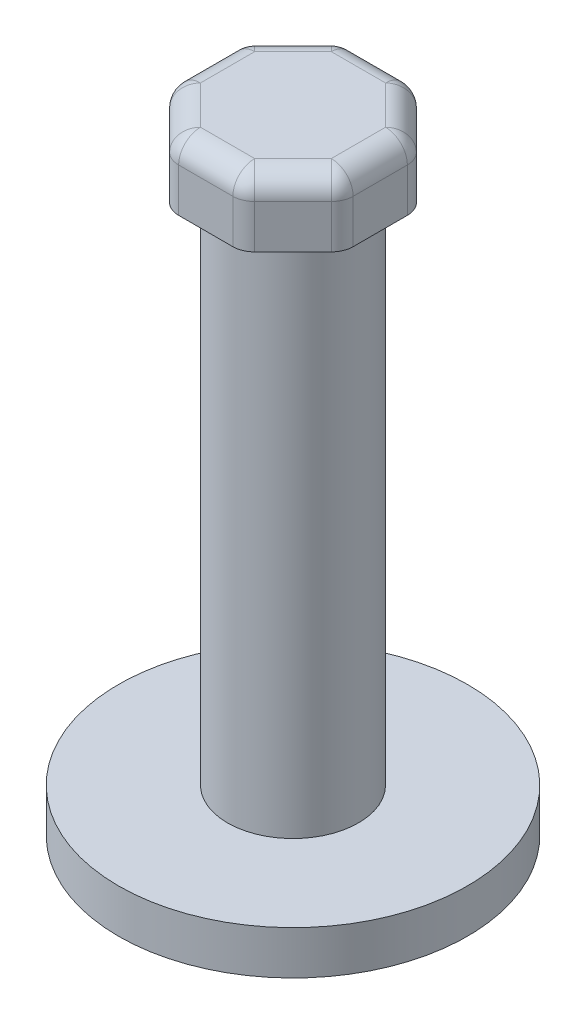
from build123d import *

# Parameters (mm, degrees)
SKETCH1_R           = 10.16
BOSS_EXTRUDE1_DEPTH = 2.54
SKETCH2_R           = 3.81
BOSS_EXTRUDE2_DEPTH = 30.48
BOSS_EXTRUDE3_DEPTH = 3.81
FILLET1_R           = 1.27


with BuildPart() as part:
    # Sketch1 → Boss-Extrude1 (new body)
    with BuildSketch(Plane(origin=(0, 0, 0), x_dir=(1, 0, 0), z_dir=(0, 1, 0))):
        Circle(SKETCH1_R)
    extrude(amount=BOSS_EXTRUDE1_DEPTH)

    # Sketch2 → Boss-Extrude2 (add)
    with BuildSketch(Plane(origin=(0, 2.54, 0), x_dir=(1, 0, 0), z_dir=(0, 1, 0))):
        Circle(SKETCH2_R)
    extrude(amount=BOSS_EXTRUDE2_DEPTH)

    # Sketch3 → Boss-Extrude3 (add)
    with BuildSketch(Plane(origin=(0, 33.02, 0), x_dir=(1, 0, 0), z_dir=(0, 1, 0))):
        Polygon((2.104204897, 5.08), (-2.104204897, 5.08), (-5.08, 2.104204897), (-5.08, -2.104204897), (-2.104204897, -5.08), (2.104204897, -5.08), (5.08, -2.104204897), (5.08, 2.104204897), align=None)
    extrude(amount=BOSS_EXTRUDE3_DEPTH)

    # Fillet1
    fillet1_edges = [part.edges().sort_by_distance(p)[0] for p in [
        (5.08, 34.925, -2.104204897),
        (2.104204897, 34.925, -5.08),
        (-2.104204897, 34.925, -5.08),
        (-5.08, 34.925, -2.104204897),
        (-5.08, 34.925, 2.104204897),
        (-2.104204897, 34.925, 5.08),
        (2.104204897, 34.925, 5.08),
        (5.08, 34.925, 2.104204897),
        (3.592102448, 36.83, -3.592102448),
        (0, 36.83, -5.08),
        (-3.592102448, 36.83, -3.592102448),
        (-5.08, 36.83, 0),
        (-3.592102448, 36.83, 3.592102448),
        (0, 36.83, 5.08),
        (3.592102448, 36.83, 3.592102448),
        (5.08, 36.83, 0),
    ]]
    fillet(fillet1_edges, radius=FILLET1_R)


solid = part.part
